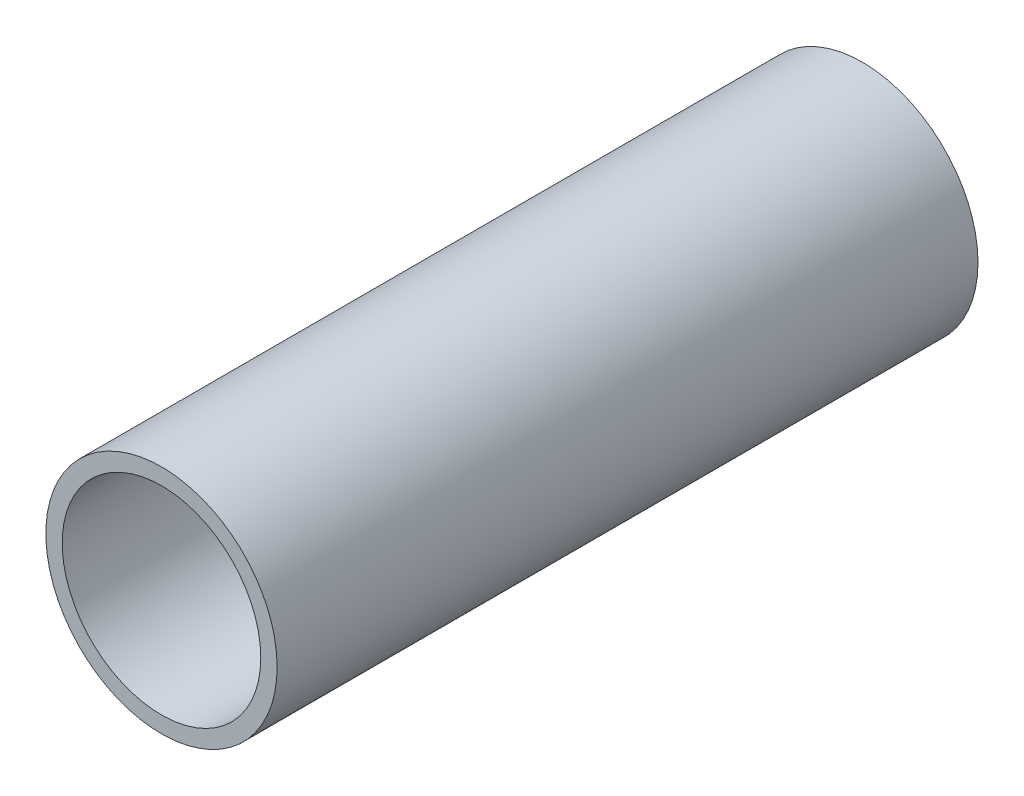
from build123d import *

# Parameters (mm, degrees)
SKETCH1_R           = 12.573
SKETCH1_R_2         = 10.795
BOSS_EXTRUDE1_DEPTH = 76.2


with BuildPart() as part:
    # Sketch1 → Boss-Extrude1 (new body)
    with BuildSketch(Plane.XY):
        Circle(SKETCH1_R)
        Circle(SKETCH1_R_2, mode=Mode.SUBTRACT)
    extrude(amount=BOSS_EXTRUDE1_DEPTH)


solid = part.part
